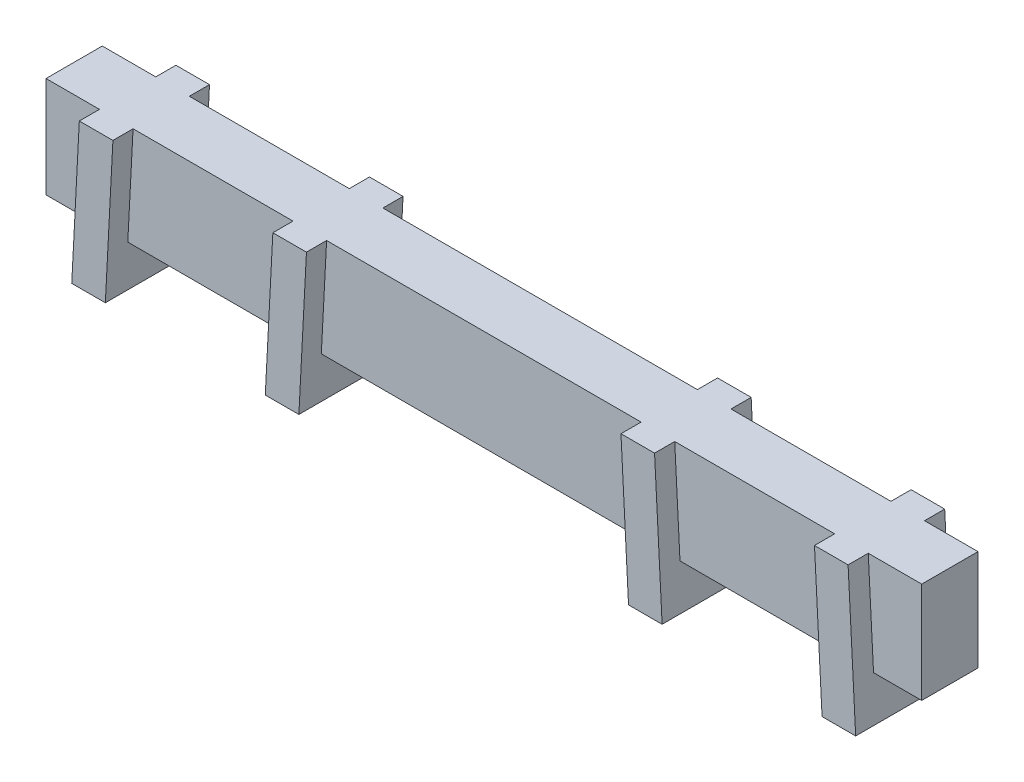
from build123d import *

# Parameters (mm, degrees)
SKETCH1_W           = 66.20002
SKETCH1_H           = 4.2545
BOSS_EXTRUDE1_DEPTH = 7.62
SKETCH3_W           = 7.3025
SKETCH3_H           = 12.7
BOSS_EXTRUDE2_DEPTH = 2.54
SKETCH7_W           = 7.3025
SKETCH7_H           = 12.7
BOSS_EXTRUDE3_DEPTH = 2.54
SKETCH8_W           = 7.3025
SKETCH8_H           = 12.7
BOSS_EXTRUDE4_DEPTH = 2.54
SKETCH9_W           = 7.3025
SKETCH9_H           = 12.7
BOSS_EXTRUDE5_DEPTH = 2.54
SKETCH10_W          = 66.20002
SKETCH10_H          = 20.74309717
CUT_EXTRUDE1_DEPTH  = 8.709364346
SKETCH11_W          = 2.54
SKETCH11_H          = 7.3025
BOSS_EXTRUDE6_DEPTH = 2.978912
SKETCH12_W          = 2.54
SKETCH12_H          = 7.3025
BOSS_EXTRUDE7_DEPTH = 5.94868
SKETCH13_W          = 2.54
SKETCH13_H          = 7.3025
BOSS_EXTRUDE8_DEPTH = 0.074168
SKETCH14_W          = 2.54
SKETCH14_H          = 7.3025
BOSS_EXTRUDE9_DEPTH = 2.978912


with BuildPart() as part:
    # Sketch1 → Boss-Extrude1 (new body)
    with BuildSketch(Plane(origin=(0, 0, 0), x_dir=(1, 0, 0), z_dir=(0, 1, 0))):
        with Locations((0, -2.12725)):
            Rectangle(SKETCH1_W, SKETCH1_H)
    extrude(amount=BOSS_EXTRUDE1_DEPTH)

    # Sketch3 → Boss-Extrude2 (add, along a direction that is not the sketch's normal)
    with BuildSketch(Plane(origin=(-26.843667844, 1.40681702, 0), x_dir=(0, 0, -1), z_dir=(-0.998629535, 0.052335956, 0))):
        with Locations((-2.12725, -4.617679325)):
            Rectangle(SKETCH3_W, SKETCH3_H)
    extrude(amount=BOSS_EXTRUDE2_DEPTH, dir=(-1, 0, 0))

    # Sketch7 → Boss-Extrude3 (add, along a direction that is not the sketch's normal)
    with BuildSketch(Plane(origin=(-14.786384082, 0.774921553, 0), x_dir=(0, 0, -1), z_dir=(-0.998629535, 0.052335956, 0))):
        with Locations((-2.12725, -8.224416524)):
            Rectangle(SKETCH7_W, SKETCH7_H)
    extrude(amount=-BOSS_EXTRUDE3_DEPTH, dir=(-1, 0, 0))

    # Sketch8 → Boss-Extrude4 (add, along a direction that is not the sketch's normal)
    with BuildSketch(Plane(origin=(14.786384082, 0.774921553, 0), x_dir=(0, 0, -1), z_dir=(0.998629535, 0.052335956, 0))):
        with Locations((-2.12725, 2.341864986)):
            Rectangle(SKETCH8_W, SKETCH8_H)
    extrude(amount=-BOSS_EXTRUDE4_DEPTH, dir=(1, 0, 0))

    # Sketch9 → Boss-Extrude5 (add, along a direction that is not the sketch's normal)
    with BuildSketch(Plane(origin=(26.843667844, 1.40681702, 0), x_dir=(0, 0, -1), z_dir=(0.998629535, 0.052335956, 0))):
        with Locations((-2.12725, 4.617679325)):
            Rectangle(SKETCH9_W, SKETCH9_H)
    extrude(amount=BOSS_EXTRUDE5_DEPTH, dir=(1, 0, 0))

    # Sketch10 → Cut-Extrude1 (cut, through all)
    with BuildSketch(Plane(origin=(0, 7.62, 0), x_dir=(1, 0, 0), z_dir=(0, 1, 0))):
        with Locations((0, -1.111264459)):
            Rectangle(SKETCH10_W, SKETCH10_H)
    extrude(amount=CUT_EXTRUDE1_DEPTH, mode=Mode.SUBTRACT)

    # Sketch11 → Boss-Extrude6 (add, along a direction that is not the sketch's normal)
    with BuildSketch(Plane(origin=(0, -0.32312957, 0), x_dir=(-1, 0, 0), z_dir=(0, -1, 0))):
        with Locations((28.204330503, -2.12725)):
            Rectangle(SKETCH11_W, SKETCH11_H)
    extrude(amount=BOSS_EXTRUDE6_DEPTH, dir=(-0.052335956, -0.998629535, 0))

    # Sketch12 → Boss-Extrude7 (add, along a direction that is not the sketch's normal)
    with BuildSketch(Plane.XZ.offset(-2.646769255)):
        with Locations((-13.418284701, 2.12725)):
            Rectangle(SKETCH12_W, SKETCH12_H)
    extrude(amount=BOSS_EXTRUDE7_DEPTH, dir=(-0.052335956, -0.998629535, 0))

    # Sketch13 → Boss-Extrude8 (add, along a direction that is not the sketch's normal)
    with BuildSketch(Plane.XZ.offset(3.227720451)):
        with Locations((13.726153661, 2.12725)):
            Rectangle(SKETCH13_W, SKETCH13_H)
    extrude(amount=BOSS_EXTRUDE8_DEPTH, dir=(0.052335956, -0.998629535, 0))

    # Sketch14 → Boss-Extrude9 (add, along a direction that is not the sketch's normal)
    with BuildSketch(Plane.XZ.offset(0.32312957)):
        with Locations((28.204330503, 2.12725)):
            Rectangle(SKETCH14_W, SKETCH14_H)
    extrude(amount=BOSS_EXTRUDE9_DEPTH, dir=(0.052335956, -0.998629535, 0))


solid = part.part
